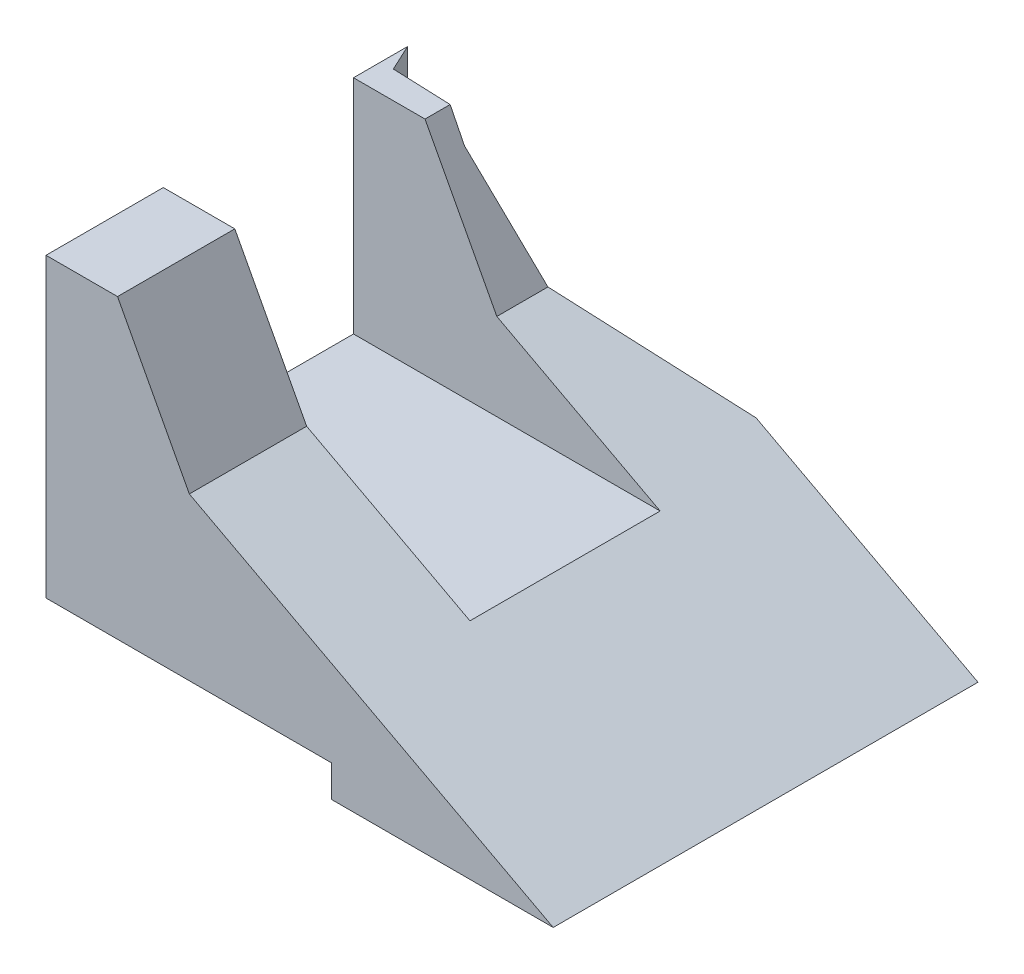
from build123d import *

# Parameters (mm, degrees)
CROQUIS1_W              = 67
CROQUIS1_H              = 51.82
SALIENTE_EXTRUIR1_DEPTH = 80
CORTAR_EXTRUIR1_REACH   = 69
CROQUIS4_W              = 60
CROQUIS4_H              = 30
CORTAR_EXTRUIR2_DEPTH   = 35
CORTAR_EXTRUIR3_REACH   = 69
CROQUIS5_W              = 45
CROQUIS5_H              = 5
CORTAR_EXTRUIR4_REACH   = 53.82
CORTAR_EXTRUIR5_REACH   = 53.82


with BuildPart() as part:
    # Croquis1 → Saliente-Extruir1 (new body)
    with BuildSketch(Plane(origin=(0, 0, 0), x_dir=(0, 0, -1), z_dir=(1, 0, 0))):
        with Locations((33.5, 25.91)):
            Rectangle(CROQUIS1_W, CROQUIS1_H)
    extrude(amount=SALIENTE_EXTRUIR1_DEPTH)

    # Croquis3 → Cortar-Extruir1 (cut, up to next)
    with BuildSketch(Plane.XY, mode=Mode.PRIVATE) as cortar_extruir1_sk1:
        Polygon((80, 0), (22.608406464, 30.515651581), (11.280683474, 51.82), (80, 51.82), align=None)
    cortar_extruir1_tool1 = extrude(cortar_extruir1_sk1.sketch, amount=-CORTAR_EXTRUIR1_REACH, mode=Mode.PRIVATE) & part.part
    add(cortar_extruir1_tool1.solids().sort_by_distance((53.313116, 33.143327, 0))[0], mode=Mode.SUBTRACT)

    # Croquis4 → Cortar-Extruir2 (cut)
    with BuildSketch(Plane(origin=(0, 51.82, 0), x_dir=(1, 0, 0), z_dir=(0, 1, 0))):
        with Locations((30, 33.5)):
            Rectangle(CROQUIS4_W, CROQUIS4_H)
    extrude(amount=-CORTAR_EXTRUIR2_DEPTH, mode=Mode.SUBTRACT)

    # Croquis5 → Cortar-Extruir3 (cut, up to next)
    with BuildSketch(Plane.XY, mode=Mode.PRIVATE) as cortar_extruir3_sk1:
        with Locations((22.5, 2.5)):
            Rectangle(CROQUIS5_W, CROQUIS5_H)
    cortar_extruir3_tool1 = extrude(cortar_extruir3_sk1.sketch, amount=-CORTAR_EXTRUIR3_REACH, mode=Mode.PRIVATE) & part.part
    add(cortar_extruir3_tool1.solids().sort_by_distance((22.5, 2.5, 0))[0], mode=Mode.SUBTRACT)

    # Croquis6 → Cortar-Extruir4 (cut, up to next)
    with BuildSketch(Plane(origin=(0, 51.82, 0), x_dir=(1, 0, 0), z_dir=(0, 1, 0)), mode=Mode.PRIVATE) as cortar_extruir4_sk1:
        Polygon((4.922856145, 67), (0, 64.334655313), (0, 67), align=None)
    cortar_extruir4_tool1 = extrude(cortar_extruir4_sk1.sketch, amount=-CORTAR_EXTRUIR4_REACH, mode=Mode.PRIVATE) & part.part
    add(cortar_extruir4_tool1.solids().sort_by_distance((1.640952, 51.82, -66.111552))[0], mode=Mode.SUBTRACT)

    # Croquis9 → Cortar-Extruir5 (cut, up to next)
    with BuildSketch(Plane(origin=(0, 51.82, 0), x_dir=(1, 0, 0), z_dir=(0, 1, 0)), mode=Mode.PRIVATE) as cortar_extruir5_sk1:
        Polygon((45, 67), (13.626202653, 52.370158031), (1.954435626, 52.832439456), (-4.658833913, 67.014641749), align=None)
    cortar_extruir5_tool1 = extrude(cortar_extruir5_sk1.sketch, amount=-CORTAR_EXTRUIR5_REACH, mode=Mode.PRIVATE) & part.part
    add(cortar_extruir5_tool1.solids().sort_by_distance((15.368059, 51.82, -61.265598))[0], mode=Mode.SUBTRACT)


solid = part.part
